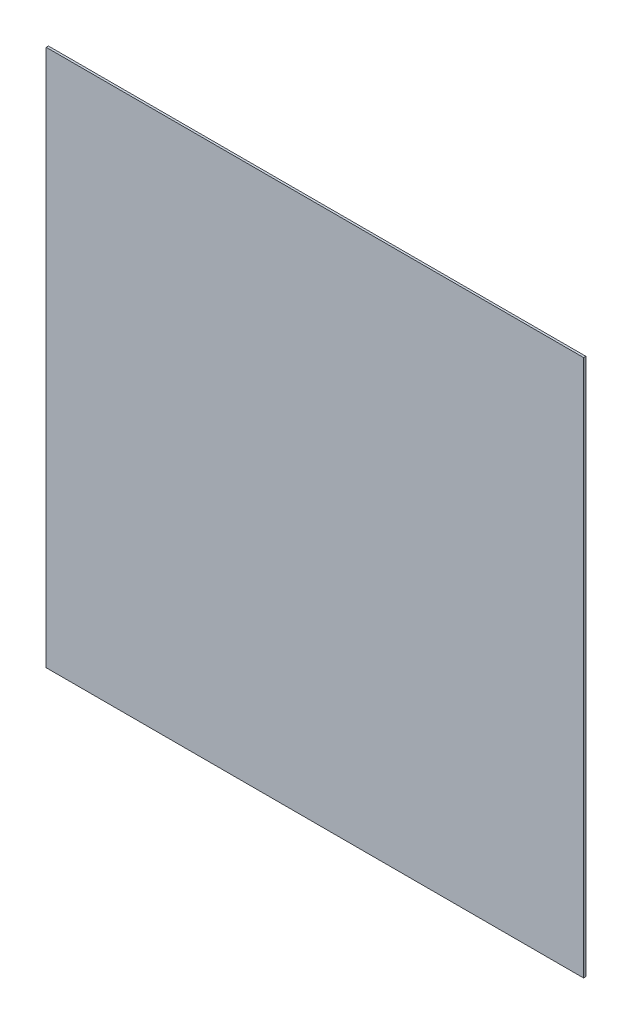
from build123d import *

# Parameters (mm, degrees)
SKETCH1_W           = 762
SKETCH1_H           = 762
BOSS_EXTRUDE1_DEPTH = 3.175


with BuildPart() as part:
    # Sketch1 → Boss-Extrude1 (new body)
    with BuildSketch(Plane.XY):
        with Locations((381, 381)):
            Rectangle(SKETCH1_W, SKETCH1_H)
    extrude(amount=BOSS_EXTRUDE1_DEPTH)


solid = part.part
